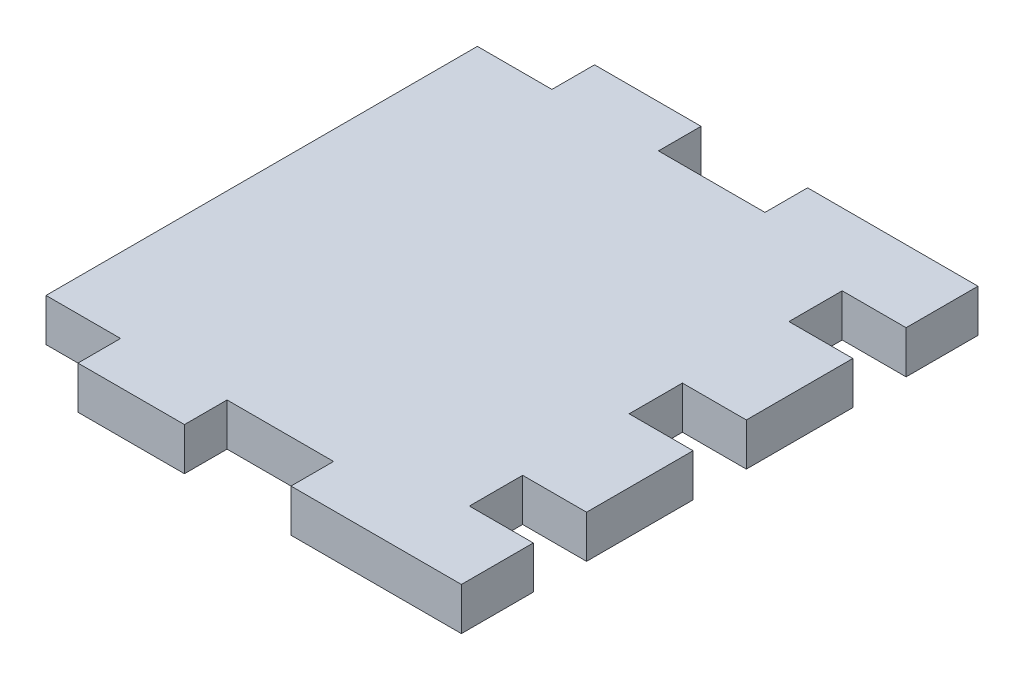
from build123d import *

# Parameters (mm, degrees)
SKETCH1_W           = 37
SKETCH1_H           = 40.5
BOSS_EXTRUDE1_DEPTH = 4
SKETCH2_W           = 10
SKETCH2_H           = 4
BOSS_EXTRUDE2_DEPTH = 4
LPATTERN1_COUNT     = 2
LPATTERN1_PITCH     = 20
SKETCH3_W           = 6.75
SKETCH3_H           = 4
SKETCH3_W_2         = 10
BOSS_EXTRUDE3_DEPTH = 6


with BuildPart() as part:
    # Sketch1 → Boss-Extrude1 (new body)
    with BuildSketch(Plane(origin=(0, 0, 0), x_dir=(1, 0, 0), z_dir=(0, 1, 0))):
        with Locations((18.5, -20.25)):
            Rectangle(SKETCH1_W, SKETCH1_H)
    extrude(amount=BOSS_EXTRUDE1_DEPTH)

    # Sketch2 → Boss-Extrude2 (add, through all)
    with BuildSketch(Plane(origin=(0, 0, 0), x_dir=(-1, 0, 0), z_dir=(0, -1, 0))):
        with Locations((-32, 2)):
            Rectangle(SKETCH2_W, SKETCH2_H)
        with Locations((-32, -42.5)):
            Rectangle(SKETCH2_W, SKETCH2_H)
    boss_extrude2 = extrude(amount=-BOSS_EXTRUDE2_DEPTH)

    # LPattern1: Boss-Extrude2 ×2
    with Locations(*[(-i * LPATTERN1_PITCH, 0, 0) for i in range(1, LPATTERN1_COUNT)]):
        add(boss_extrude2)

    # Sketch3 → Boss-Extrude3 (add)
    with BuildSketch(Plane(origin=(37, 0, 0), x_dir=(0, 0, -1), z_dir=(1, 0, 0))):
        with Locations((0.625, 2)):
            Rectangle(SKETCH3_W, SKETCH3_H)
        with Locations((-12.75, 2)):
            Rectangle(SKETCH3_W_2, SKETCH3_H)
        with Locations((-27.75, 2)):
            Rectangle(SKETCH3_W_2, SKETCH3_H)
        with Locations((-41.125, 2)):
            Rectangle(SKETCH3_W, SKETCH3_H)
    extrude(amount=BOSS_EXTRUDE3_DEPTH)


solid = part.part
